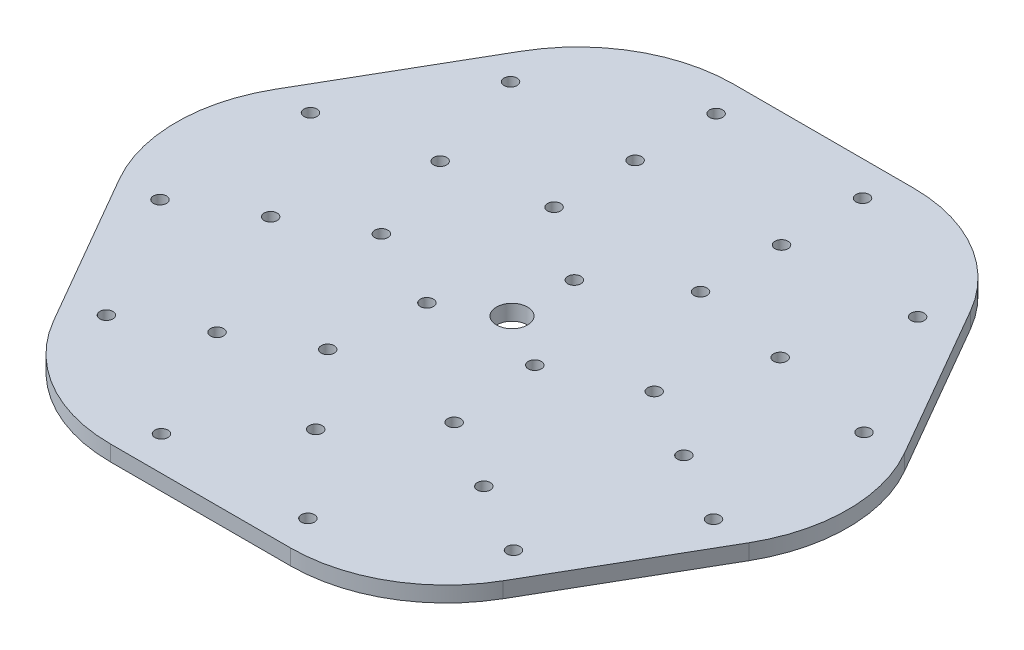
from build123d import *

# Parameters (mm, degrees)
EXTRUDE_1_DEPTH          = 5
SKETCH_2_R               = 2.1
CUT_EXTRUDE_1_DEPTH      = 153.834332967
PATTERN_CIRCULAR_1_COUNT = 3
SKETCH_3_R               = 2.1
CUT_EXTRUDE_2_DEPTH      = 153.834332967
PATTERN_CIRCULAR_2_COUNT = 3
SKETCH_4_R               = 2.1
CUT_EXTRUDE_3_DEPTH      = 153.834332967
PATTERN_CIRCULAR_3_COUNT = 3
FILLET_1_R               = 50
CUT_EXTRUDE_4_DEPTH      = 148.077653045
CUT_EXTRUDE_4_DEPTH_BACK = 148.077653045
SKETCH_5_R               = 5


with BuildPart() as part:
    # 草图1 → 凸台-拉伸1 (new body)
    with BuildSketch(Plane(origin=(0, 0, 0), x_dir=(1, 0, 0), z_dir=(0, 1, 0))):
        Polygon((57.735026919, 100), (-57.735026919, 100), (-115.470053838, 0), (-57.735026919, -100), (57.735026919, -100), (115.470053838, 0), align=None)
    extrude(amount=EXTRUDE_1_DEPTH)

    # 草图2 → 切除-拉伸1 (cut, through all)
    with BuildSketch(Plane(origin=(0, 5, 0), x_dir=(1, 0, 0), z_dir=(0, 1, 0))):
        with Locations((-23.5, 37)):
            Circle(SKETCH_2_R)
        with Locations((23.5, 37)):
            Circle(SKETCH_2_R)
        with Locations((-23.5, 63)):
            Circle(SKETCH_2_R)
        with Locations((23.5, 63)):
            Circle(SKETCH_2_R)
        with Locations((-23.5, 89)):
            Circle(SKETCH_2_R)
        with Locations((23.5, 89)):
            Circle(SKETCH_2_R)
    cut_extrude_1 = extrude(amount=-CUT_EXTRUDE_1_DEPTH, mode=Mode.SUBTRACT)

    # 阵列(圆周)1: 切除-拉伸1 ×3 about axis
    pattern_circular_1_axis = Axis((0, -75.806700776, 0), (0, 1, 0))
    for i in range(1, PATTERN_CIRCULAR_1_COUNT):
        add(cut_extrude_1.rotate(pattern_circular_1_axis, i * 360 / PATTERN_CIRCULAR_1_COUNT), mode=Mode.SUBTRACT)

    # 草图3 → 切除-拉伸2 (cut, through all)
    with BuildSketch(Plane(origin=(0, 5, 0), x_dir=(1, 0, 0), z_dir=(0, 1, 0))):
        with Locations((65.326260937, 64.851596989)):
            Circle(SKETCH_3_R)
        with Locations((88.826260937, 24.148403011)):
            Circle(SKETCH_3_R)
        with Locations((54.559600438, 31.5)):
            Circle(SKETCH_3_R)
    cut_extrude_2 = extrude(amount=-CUT_EXTRUDE_2_DEPTH, mode=Mode.SUBTRACT)

    # 阵列(圆周)2: 切除-拉伸2 ×3 about axis
    pattern_circular_2_axis = Axis((0, -75.806700776, 0), (0, 1, 0))
    for i in range(1, PATTERN_CIRCULAR_2_COUNT):
        add(cut_extrude_2.rotate(pattern_circular_2_axis, i * 360 / PATTERN_CIRCULAR_2_COUNT), mode=Mode.SUBTRACT)

    # 草图4 → 切除-拉伸3 (cut, through all)
    with BuildSketch(Plane(origin=(0, 5, 0), x_dir=(1, 0, 0), z_dir=(0, 1, 0))):
        with Locations((0, 20)):
            Circle(SKETCH_4_R)
    cut_extrude_3 = extrude(amount=-CUT_EXTRUDE_3_DEPTH, mode=Mode.SUBTRACT)

    # 阵列(圆周)3: 切除-拉伸3 ×3 about axis
    pattern_circular_3_axis = Axis((0, -75.806700776, 0), (0, 1, 0))
    for i in range(1, PATTERN_CIRCULAR_3_COUNT):
        add(cut_extrude_3.rotate(pattern_circular_3_axis, i * 360 / PATTERN_CIRCULAR_3_COUNT), mode=Mode.SUBTRACT)

    # 圆角1
    fillet_1_edges = [part.edges().sort_by_distance(p)[0] for p in [
        (57.735026919, 2.5, -100),
        (-57.735026919, 2.5, -100),
        (-115.470053838, 2.5, 0),
        (-57.735026919, 2.5, 100),
        (57.735026919, 2.5, 100),
        (115.470053838, 2.5, 0),
    ]]
    fillet(fillet_1_edges, radius=FILLET_1_R)

    # 草图5 → 切除-拉伸4 (cut, two sides: drawn at the far end of the back side and taken through both)
    with BuildSketch(Plane(origin=(0, 5, 0), x_dir=(1, 0, 0), z_dir=(0, 1, 0)).offset(-CUT_EXTRUDE_4_DEPTH_BACK)):
        Circle(SKETCH_5_R)
    extrude(amount=CUT_EXTRUDE_4_DEPTH + CUT_EXTRUDE_4_DEPTH_BACK, mode=Mode.SUBTRACT)


solid = part.part
